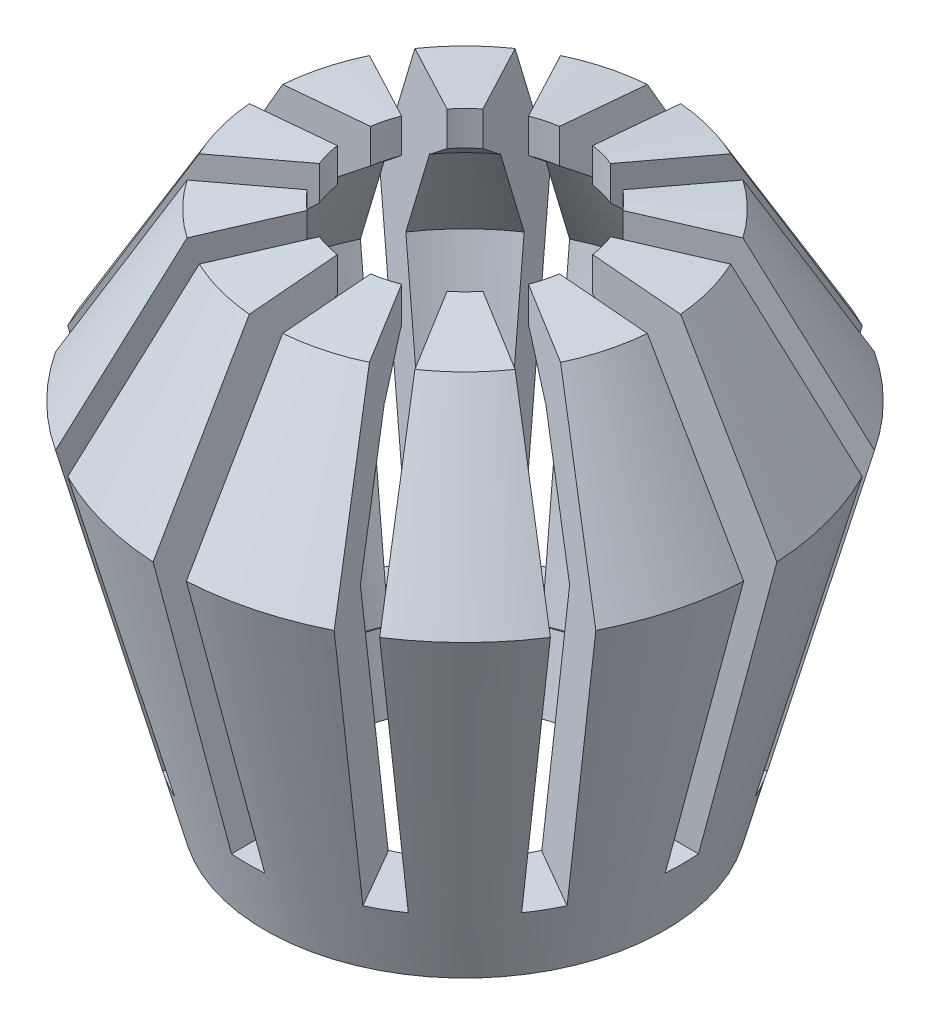
from build123d import *

# Parameters (mm, degrees)
SKETCH_6_R               = 6.75
CUT_EXTRUDE_3_DEPTH      = 2.049864
CUT_EXTRUDE_3_DEPTH_BACK = 32.547005
SKETCH_8_W               = 2
SKETCH_8_H               = 35.547006
SKETCH_8_W_2             = 35.547006
SKETCH_8_H_2             = 2
CUT_EXTRUDE_4_DEPTH      = 1.459315
CUT_EXTRUDE_4_DEPTH_BACK = 27.547005


with BuildPart() as part:
    # 草图2 → 旋转1 (revolve)
    with BuildSketch(Plane.XY):
        Polygon((0, 11.049864), (0, 10), (-12, 10), align=None)
        Polygon((0, 10), (0, -21.547005), (-12, -21.547005), (-17.773503, 0), (-12, 10), align=None)
    revolve(axis=Axis((0, -736.81226, 0), (0, 1, 0)))

    # 草图7 one side → 切除-旋转2 (revolve, cut)
    with BuildSketch(Plane.XY):
        Polygon((0, -17.547005), (0, 7.034585), (-9.577032, 6.196703), (-13.480974, -0.565122), (-8.930692, -17.547005), align=None)
    revolve(axis=Axis((0, -1000, 0), (0, 1, 0)), mode=Mode.SUBTRACT)

    # 草图6 → 切除-拉伸3 (cut, two sides)
    with BuildSketch(Plane(origin=(0, 10, 0), x_dir=(1, 0, 0), z_dir=(0, 1, 0))) as cut_extrude_3_sk:
        Circle(SKETCH_6_R)
    extrude(amount=CUT_EXTRUDE_3_DEPTH, mode=Mode.SUBTRACT)
    extrude(cut_extrude_3_sk.sketch, amount=-CUT_EXTRUDE_3_DEPTH_BACK, mode=Mode.SUBTRACT)

    # 草图8 → 切除-拉伸4 (cut, two sides)
    with BuildSketch(Plane(origin=(0, 10, 0), x_dir=(1, 0, 0), z_dir=(0, 1, 0))) as cut_extrude_4_sk:
        Polygon((9.752777, 14.892305), (-8.020726, -15.892305), (-9.752777, -14.892305), (8.020726, 15.892305), align=None)
        Rectangle(SKETCH_8_W, SKETCH_8_H)
        Polygon((15.892305, 8.020726), (-14.892305, -9.752777), (-15.892305, -8.020726), (14.892305, 9.752777), align=None)
        Rectangle(SKETCH_8_W_2, SKETCH_8_H_2)
        Polygon((14.892305, -9.752777), (-15.892305, 8.020726), (-14.892305, 9.752777), (15.892305, -8.020726), align=None)
        Polygon((8.020726, -15.892305), (-9.752777, 14.892305), (-8.020726, 15.892305), (9.752777, -14.892305), align=None)
    extrude(amount=CUT_EXTRUDE_4_DEPTH, mode=Mode.SUBTRACT)
    extrude(cut_extrude_4_sk.sketch, amount=-CUT_EXTRUDE_4_DEPTH_BACK, mode=Mode.SUBTRACT)

    # 草图10 → 切除-旋转3 (revolve, cut)
    with BuildSketch(Plane.XY):
        with BuildLine():
            Line((6.675515, 8.459315), (6.675515, 6.444036))
            add(Edge.make_bspline(
                [(9.524681, 6.196703), (8.574975, 6.279337), (7.625259, 6.361861), (6.675515, 6.444036)],
                knots=[0, 0, 0, 0, 1, 1, 1, 1], degree=3))
            Line((9.524681, 6.196703), (6.675515, 8.459315))
        make_face()
    revolve(axis=Axis((0, -1000, 0), (0, 1, 0)), mode=Mode.SUBTRACT)

    # 草图11 → 切除-旋转4 (revolve, cut)
    with BuildSketch(Plane.XY):
        Polygon((6.75, -21.547005), (6.75, -17.547005), (8.874529, -17.547005), (7.795949, -21.547005), align=None)
    revolve(axis=Axis((0, -1000, 0), (0, 1, 0)), mode=Mode.SUBTRACT)


solid = part.part
